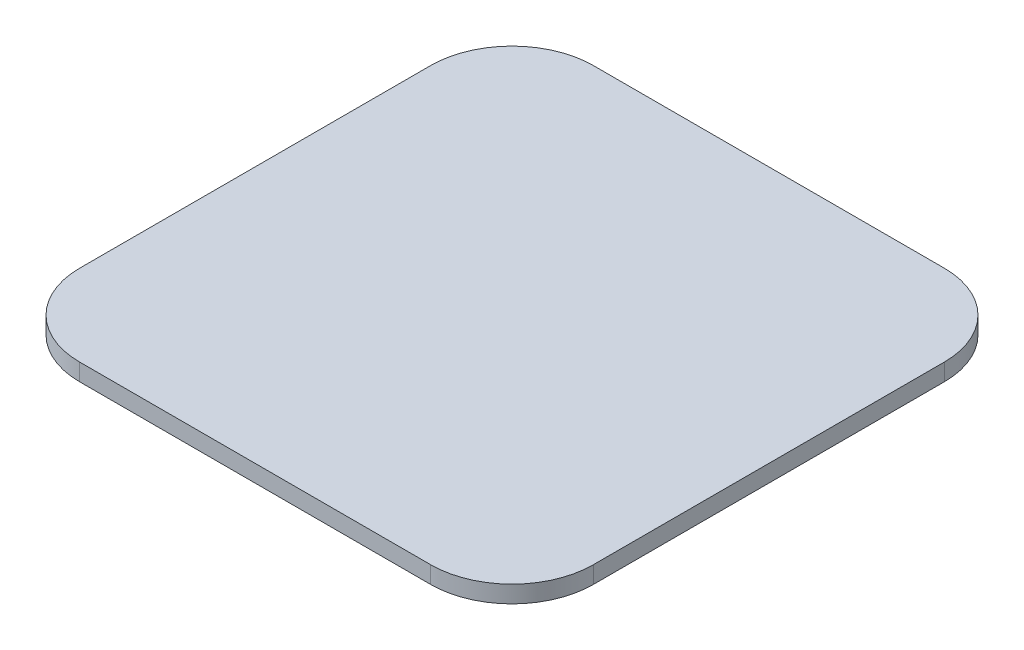
from build123d import *

# Parameters (mm, degrees)
SKETCH1_W           = 120
SKETCH1_H           = 120
BOSS_EXTRUDE1_DEPTH = 4
FILLET1_R           = 19


with BuildPart() as part:
    # Sketch1 → Boss-Extrude1 (new body)
    with BuildSketch(Plane(origin=(0, 0, 0), x_dir=(1, 0, 0), z_dir=(0, 1, 0))):
        with Locations((60, 60)):
            Rectangle(SKETCH1_W, SKETCH1_H)
    extrude(amount=BOSS_EXTRUDE1_DEPTH)

    # Fillet1
    fillet1_edges = [part.edges().sort_by_distance(p)[0] for p in [
        (0, 2, -120),
        (120, 2, -120),
        (120, 2, 0),
        (0, 2, 0),
    ]]
    fillet(fillet1_edges, radius=FILLET1_R)


solid = part.part
